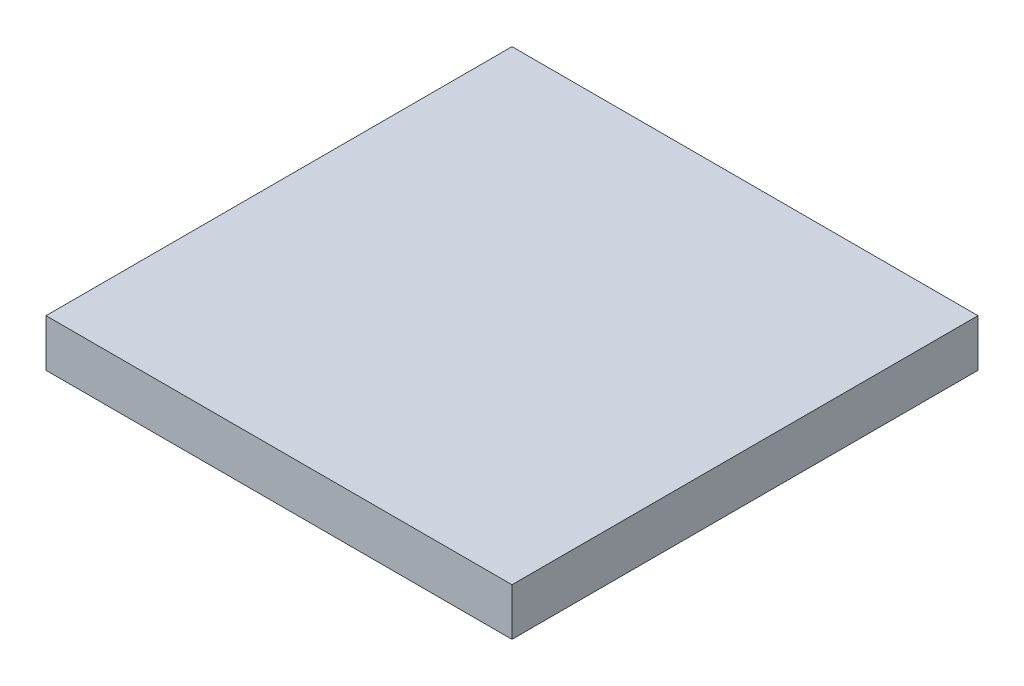
from build123d import *

# Parameters (mm, degrees)
SKETCH1_W           = 33.528
SKETCH1_H           = 5.08
BOSS_EXTRUDE1_DEPTH = 13.97
SKETCH2_W           = 50
SKETCH2_H           = 50
BOSS_EXTRUDE2_DEPTH = 5.08


with BuildPart() as part:
    # Sketch1 → Boss-Extrude1 (new body)
    with BuildSketch(Plane(origin=(0, 0, 0), x_dir=(1, 0, 0), z_dir=(0, 1, 0))):
        Rectangle(SKETCH1_W, SKETCH1_H)
    extrude(amount=BOSS_EXTRUDE1_DEPTH)

    # Sketch2 → Boss-Extrude2 (add)
    with BuildSketch(Plane(origin=(0, 13.97, 0), x_dir=(1, 0, 0), z_dir=(0, 1, 0))):
        with Locations((8.236, -22.46)):
            Rectangle(SKETCH2_W, SKETCH2_H)
    extrude(amount=BOSS_EXTRUDE2_DEPTH)


solid = part.part
